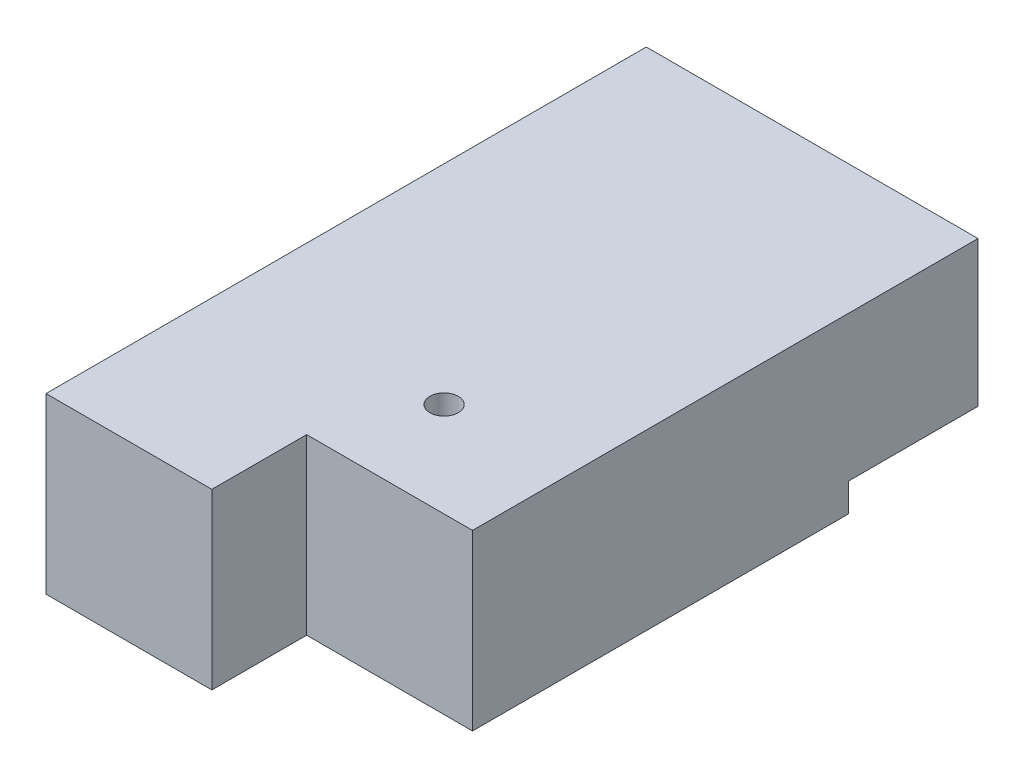
from build123d import *

# Parameters (mm, degrees)
SKETCH_1_W          = 21
SKETCH_1_H          = 38
EXTRUDE_1_DEPTH     = 11
SKETCH_2_W          = 21
SKETCH_2_H          = 8.2
CUT_EXTRUDE_1_DEPTH = 1.8
SKETCH_3_W          = 10.5
SKETCH_3_H          = 11
CUT_EXTRUDE_2_DEPTH = 6
SKETCH_5_R          = 0.9
CUT_EXTRUDE_3_DEPTH = 12


with BuildPart() as part:
    # 草图1 → 凸台-拉伸1 (new body)
    with BuildSketch(Plane(origin=(0, 0, 0), x_dir=(1, 0, 0), z_dir=(0, 1, 0))):
        Rectangle(SKETCH_1_W, SKETCH_1_H)
    extrude(amount=EXTRUDE_1_DEPTH)

    # 草图2 → 切除-拉伸1 (cut)
    with BuildSketch(Plane.XZ):
        with Locations((0, -14.9)):
            Rectangle(SKETCH_2_W, SKETCH_2_H)
    extrude(amount=-CUT_EXTRUDE_1_DEPTH, mode=Mode.SUBTRACT)

    # 草图3 → 切除-拉伸2 (cut)
    with BuildSketch(Plane.XY.offset(19)):
        with Locations((5.25, 5.5)):
            Rectangle(SKETCH_3_W, SKETCH_3_H)
    extrude(amount=-CUT_EXTRUDE_2_DEPTH, mode=Mode.SUBTRACT)

    # 草图5 → 切除-拉伸3 (cut, through all)
    with BuildSketch(Plane(origin=(0, 11, 0), x_dir=(1, 0, 0), z_dir=(0, 1, 0))):
        with Locations((2.7, -7)):
            Circle(SKETCH_5_R)
    extrude(amount=-CUT_EXTRUDE_3_DEPTH, mode=Mode.SUBTRACT)


solid = part.part
